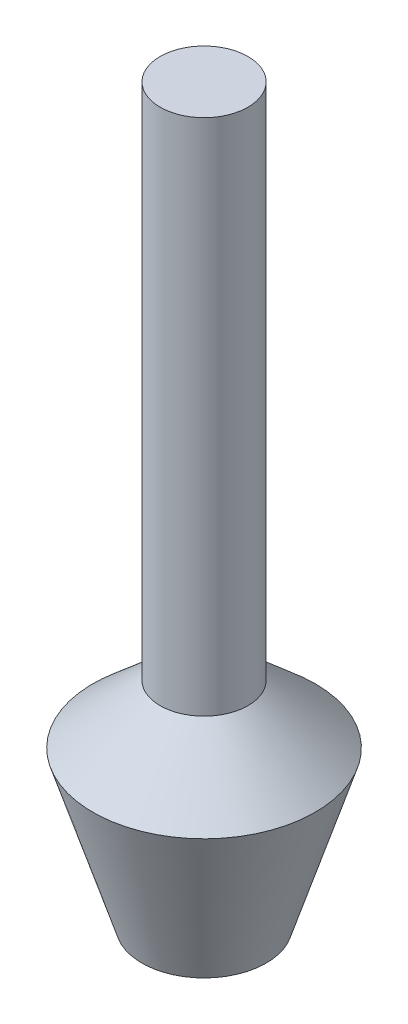
from build123d import *


with BuildPart() as part:
    # Sketch1 → Base-Revolve (revolve)
    with BuildSketch(Plane.XY):
        Polygon((3.81, 63.5), (3.81, 18.542), (9.652, 13.462), (5.3975, 0), (0, 0), (0, 63.5), align=None)
    revolve(axis=Axis((0, 0, 0), (0, 1, 0)))


solid = part.part
